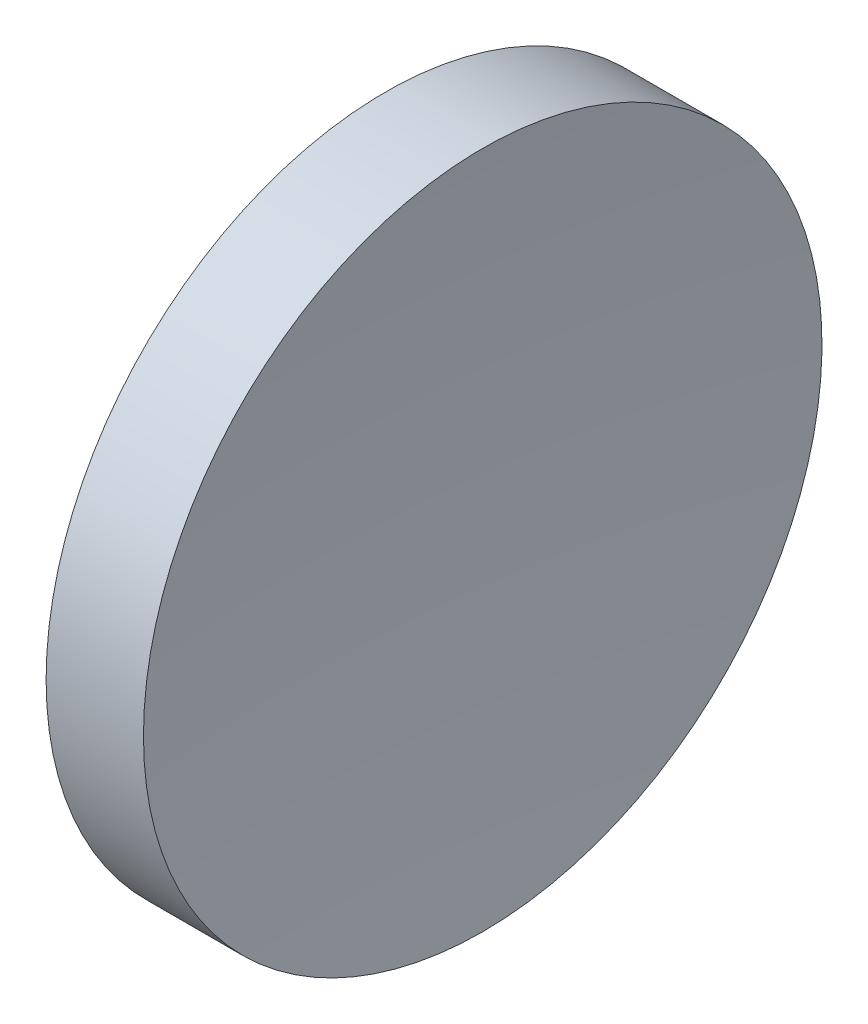
from build123d import *


with BuildPart() as part:
    # 草图1 → 旋转1 (revolve)
    with BuildSketch(Plane.XY, mode=Mode.PRIVATE) as revolve_1_sk:
        with BuildLine():
            Line((230.199611905, 138.756042247), (230.199611905, 176.256042247))
            Line((230.199611905, 176.256042247), (240.961303848, 176.256042247))
            ThreePointArc((240.961303848, 176.256042247), (239.64027762, 157.526721234), (239.1996119, 138.756042247))
            Line((239.1996119, 138.756042247), (230.199611905, 138.756042247))
        make_face()
    revolve(revolve_1_sk.sketch.rotate(Axis((217.970286004, 138.756042247, 0), (1, 0, 0)), 180), axis=Axis((217.970286004, 138.756042247, 0), (1, 0, 0)))  # turned: the seam where the file's is


solid = part.part
